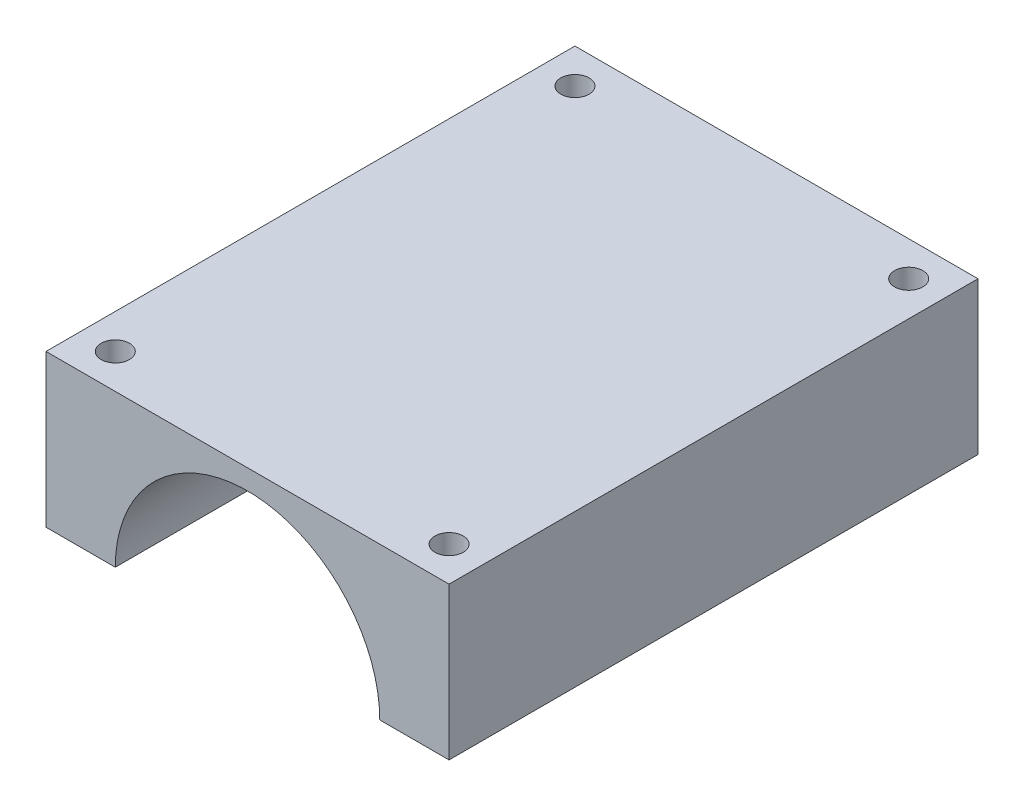
from build123d import *

# Parameters (mm, degrees)
SKETCH1_W                                  = 57.15
SKETCH1_H                                  = 75
BOSS_EXTRUDE1_DEPTH                        = 21.59
CUT_EXTRUDE1_REACH                         = 77
SKETCH5_R                                  = 2.008
CUT_EXTRUDE5_DEPTH                         = 21.59
MIRROR1_AT_THE_SECOND_PLANE_COPY_1_SKETC_R = 2.008
MIRROR1_AT_THE_SECOND_PLANE_COPY_1_DEPTH   = 21.59


with BuildPart() as part:
    # Sketch1 → Boss-Extrude1 (new body)
    with BuildSketch(Plane(origin=(0, 0, 0), x_dir=(1, 0, 0), z_dir=(0, 1, 0))):
        Rectangle(SKETCH1_W, SKETCH1_H)
    extrude(amount=BOSS_EXTRUDE1_DEPTH)

    # Sketch3 → Cut-Extrude1 (cut, up to next)
    with BuildSketch(Plane.XY.offset(37.5), mode=Mode.PRIVATE) as cut_extrude1_sk1:
        with BuildLine():
            Line((-18.75, 0), (18.75, 0))
            ThreePointArc((18.75, 0), (0, 18.75), (-18.75, 0))
        make_face()
    cut_extrude1_tool1 = extrude(cut_extrude1_sk1.sketch, amount=-CUT_EXTRUDE1_REACH, mode=Mode.PRIVATE) & part.part
    add(cut_extrude1_tool1.solids().sort_by_distance((0, 7.957747, 37.5))[0], mode=Mode.SUBTRACT)

    # Sketch5 → Cut-Extrude5 (cut)
    with BuildSketch(Plane(origin=(0, 21.59, 0), x_dir=(1, 0, 0), z_dir=(0, 1, 0))):
        with Locations((-23.6625, -32.5875)):
            Circle(SKETCH5_R)
    cut_extrude5 = extrude(amount=-CUT_EXTRUDE5_DEPTH, mode=Mode.SUBTRACT)

    # Mirror1: Cut-Extrude5 across plane
    add(cut_extrude5.mirror(Plane(origin=(0, 0, 0), x_dir=(0, 0, 1), z_dir=(1, 0, 0))), mode=Mode.SUBTRACT)

    # Mirror1 at the second plane: Cut-Extrude5 across plane
    add(cut_extrude5.mirror(Plane.XY), mode=Mode.SUBTRACT)

    # Mirror1 at the second plane copy 1 sketc → Mirror1 at the second plane copy 1 (cut)
    with BuildSketch(Plane(origin=(0, 21.59, 0), x_dir=(-1, 0, 0), z_dir=(0, 1, 0))):
        with Locations((-23.6625, -32.5875)):
            Circle(MIRROR1_AT_THE_SECOND_PLANE_COPY_1_SKETC_R)
    extrude(amount=-MIRROR1_AT_THE_SECOND_PLANE_COPY_1_DEPTH, mode=Mode.SUBTRACT)


solid = part.part
